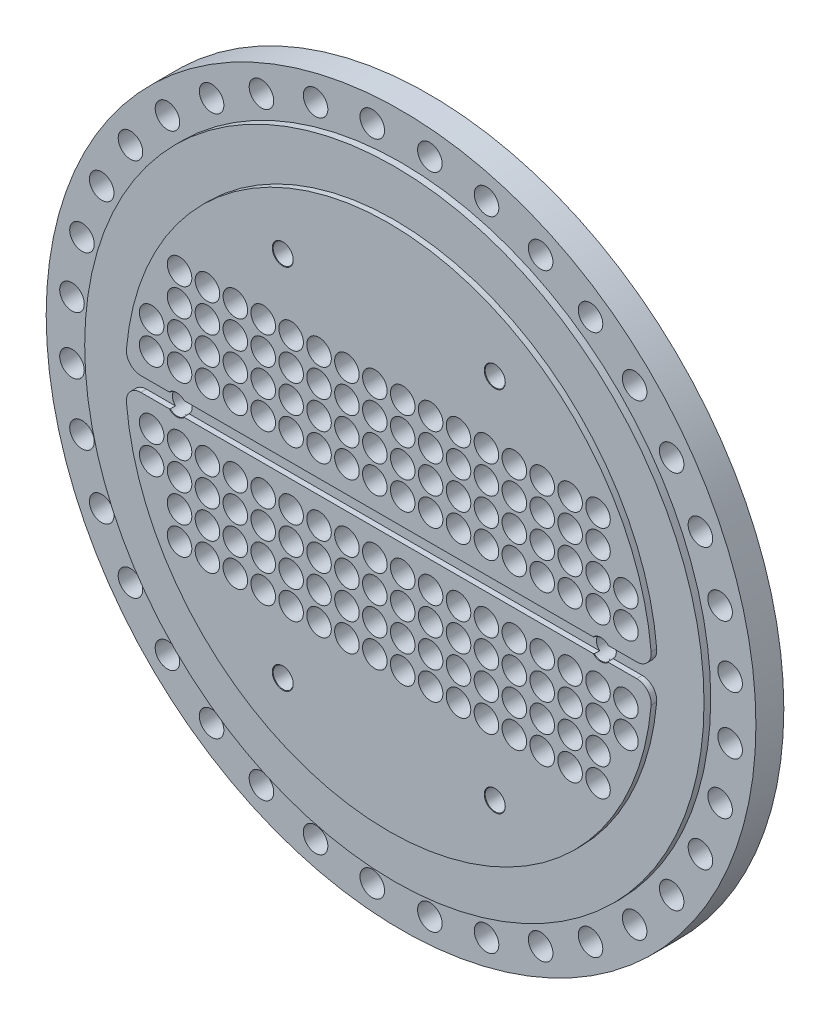
from build123d import *

# Parameters (mm, degrees)
SKETCH1_R                         = 318
BOSS_EXTRUDE1_DEPTH               = 12.5
SKETCH1_3_R                       = 277.5
BOSS_EXTRUDE2_DEPTH               = 18.5
BOSS_EXTRUDE3_DEPTH               = 23.5
SKETCH2_R                         = 11
CUT_EXTRUDE1_DEPTH                = 25
SKETCH3_R                         = 11
CUT_EXTRUDE2_DEPTH                = 47
F_3_8_NPT_TAPPED_HOLE1_AT_2_COUNT = 2
F_3_8_NPT_TAPPED_HOLE1_AT_2_PITCH = 190
F_3_8_NPT_TAPPED_HOLE1_AT_3_COUNT = 2
F_3_8_NPT_TAPPED_HOLE1_AT_3_PITCH = 329.089653438
F_3_8_NPT_TAPPED_HOLE1_AT_4_COUNT = 2
F_3_8_NPT_TAPPED_HOLE1_AT_4_PITCH = 190
F_3_8_NPT_TAPPED_HOLE1_AT_5_COUNT = 2
F_3_8_NPT_TAPPED_HOLE1_AT_5_PITCH = 329.089653438
F_3_8_NPT_TAPPED_HOLE1_AT_6_COUNT = 2
F_3_8_NPT_TAPPED_HOLE1_AT_6_PITCH = 380


with BuildPart() as part:
    # Sketch1 → Boss-Extrude1 (new body, symmetric)
    with BuildSketch(Plane.XY):
        Circle(SKETCH1_R)
    extrude(amount=BOSS_EXTRUDE1_DEPTH, both=True)

    # Sketch1_3 → Boss-Extrude2 (add, symmetric)
    with BuildSketch(Plane.XY):
        Circle(SKETCH1_3_R)
    extrude(amount=BOSS_EXTRUDE2_DEPTH, both=True)

    # Sketch1_4 → Boss-Extrude3 (add, symmetric)
    with BuildSketch(Plane.XY):
        with BuildLine():
            ThreePointArc((-235.095988205, -20.6367713), (-231.731661192, -10.718713844), (-222.145785465, -6.5))
            Line((-222.145785465, -6.5), (222.145785465, -6.5))
            ThreePointArc((222.145785465, -6.5), (231.731661192, -10.718713844), (235.095988205, -20.6367713))
            ThreePointArc((235.095988205, -20.6367713), (0, -236), (-235.095988205, -20.6367713))
        make_face()
        with BuildLine():
            ThreePointArc((235.095988205, 20.6367713), (0, 236), (-235.095988205, 20.6367713))
            ThreePointArc((-235.095988205, 20.6367713), (-231.731661192, 10.718713844), (-222.145785465, 6.5))
            Line((-222.145785465, 6.5), (222.145785465, 6.5))
            ThreePointArc((222.145785465, 6.5), (231.731661192, 10.718713844), (235.095988205, 20.6367713))
        make_face()
    extrude(amount=BOSS_EXTRUDE3_DEPTH, both=True)

    # Sketch2 → Cut-Extrude1 (cut)
    with BuildSketch(Plane.XY.offset(12.5)):
        with Locations((25.798099853, 294.873630635)):
            Circle(SKETCH2_R)
        with Locations((76.61043735, 285.914044582)):
            Circle(SKETCH2_R)
        with Locations((125.095005475, 268.267104963)):
            Circle(SKETCH2_R)
        with Locations((169.77862516, 242.46900511)):
            Circle(SKETCH2_R)
        with Locations((209.303607231, 209.303607231)):
            Circle(SKETCH2_R)
        with Locations((242.46900511, 169.77862516)):
            Circle(SKETCH2_R)
        with Locations((268.267104963, 125.095005475)):
            Circle(SKETCH2_R)
        with Locations((285.914044582, 76.61043735)):
            Circle(SKETCH2_R)
        with Locations((294.873630635, 25.798099853)):
            Circle(SKETCH2_R)
        with Locations((294.873630635, -25.798099853)):
            Circle(SKETCH2_R)
        with Locations((285.914044582, -76.61043735)):
            Circle(SKETCH2_R)
        with Locations((268.267104963, -125.095005475)):
            Circle(SKETCH2_R)
        with Locations((242.46900511, -169.77862516)):
            Circle(SKETCH2_R)
        with Locations((209.303607231, -209.303607231)):
            Circle(SKETCH2_R)
        with Locations((169.77862516, -242.46900511)):
            Circle(SKETCH2_R)
        with Locations((125.095005475, -268.267104963)):
            Circle(SKETCH2_R)
        with Locations((76.61043735, -285.914044582)):
            Circle(SKETCH2_R)
        with Locations((25.798099853, -294.873630635)):
            Circle(SKETCH2_R)
        with Locations((-25.798099853, -294.873630635)):
            Circle(SKETCH2_R)
        with Locations((-76.61043735, -285.914044582)):
            Circle(SKETCH2_R)
        with Locations((-125.095005475, -268.267104963)):
            Circle(SKETCH2_R)
        with Locations((-169.77862516, -242.46900511)):
            Circle(SKETCH2_R)
        with Locations((-209.303607231, -209.303607231)):
            Circle(SKETCH2_R)
        with Locations((-242.46900511, -169.77862516)):
            Circle(SKETCH2_R)
        with Locations((-268.267104963, -125.095005475)):
            Circle(SKETCH2_R)
        with Locations((-285.914044582, -76.61043735)):
            Circle(SKETCH2_R)
        with Locations((-294.873630635, -25.798099853)):
            Circle(SKETCH2_R)
        with Locations((-294.873630635, 25.798099853)):
            Circle(SKETCH2_R)
        with Locations((-285.914044582, 76.61043735)):
            Circle(SKETCH2_R)
        with Locations((-268.267104963, 125.095005475)):
            Circle(SKETCH2_R)
        with Locations((-242.46900511, 169.77862516)):
            Circle(SKETCH2_R)
        with Locations((-209.303607231, 209.303607231)):
            Circle(SKETCH2_R)
        with Locations((-169.77862516, 242.46900511)):
            Circle(SKETCH2_R)
        with Locations((-125.095005475, 268.267104963)):
            Circle(SKETCH2_R)
        with Locations((-76.61043735, 285.914044582)):
            Circle(SKETCH2_R)
        with Locations((-25.798099853, 294.873630635)):
            Circle(SKETCH2_R)
    extrude(amount=-CUT_EXTRUDE1_DEPTH, mode=Mode.SUBTRACT)

    # Sketch3 → Cut-Extrude2 (cut)
    with BuildSketch(Plane.XY.offset(23.5)):
        with Locations((12.5, 30)):
            Circle(SKETCH3_R)
        with Locations((37.5, 30)):
            Circle(SKETCH3_R)
        with Locations((62.5, 30)):
            Circle(SKETCH3_R)
        with Locations((87.5, 30)):
            Circle(SKETCH3_R)
        with Locations((112.5, 30)):
            Circle(SKETCH3_R)
        with Locations((137.5, 30)):
            Circle(SKETCH3_R)
        with Locations((162.5, 30)):
            Circle(SKETCH3_R)
        with Locations((187.5, 30)):
            Circle(SKETCH3_R)
        with Locations((212.5, 30)):
            Circle(SKETCH3_R)
        with Locations((37.5, 55)):
            Circle(SKETCH3_R)
        with Locations((62.5, 55)):
            Circle(SKETCH3_R)
        with Locations((87.5, 55)):
            Circle(SKETCH3_R)
        with Locations((112.5, 55)):
            Circle(SKETCH3_R)
        with Locations((137.5, 55)):
            Circle(SKETCH3_R)
        with Locations((162.5, 55)):
            Circle(SKETCH3_R)
        with Locations((187.5, 55)):
            Circle(SKETCH3_R)
        with Locations((212.5, 55)):
            Circle(SKETCH3_R)
        with Locations((37.5, 80)):
            Circle(SKETCH3_R)
        with Locations((62.5, 80)):
            Circle(SKETCH3_R)
        with Locations((87.5, 80)):
            Circle(SKETCH3_R)
        with Locations((112.5, 80)):
            Circle(SKETCH3_R)
        with Locations((137.5, 80)):
            Circle(SKETCH3_R)
        with Locations((162.5, 80)):
            Circle(SKETCH3_R)
        with Locations((187.5, 80)):
            Circle(SKETCH3_R)
        with Locations((37.5, 105)):
            Circle(SKETCH3_R)
        with Locations((62.5, 105)):
            Circle(SKETCH3_R)
        with Locations((87.5, 105)):
            Circle(SKETCH3_R)
        with Locations((112.5, 105)):
            Circle(SKETCH3_R)
        with Locations((137.5, 105)):
            Circle(SKETCH3_R)
        with Locations((162.5, 105)):
            Circle(SKETCH3_R)
        with Locations((187.5, 105)):
            Circle(SKETCH3_R)
        with Locations((12.5, 55)):
            Circle(SKETCH3_R)
        with Locations((12.5, 80)):
            Circle(SKETCH3_R)
        with Locations((12.5, 105)):
            Circle(SKETCH3_R)
        with Locations((-12.5, 105)):
            Circle(SKETCH3_R)
        with Locations((-12.5, 80)):
            Circle(SKETCH3_R)
        with Locations((-12.5, 55)):
            Circle(SKETCH3_R)
        with Locations((-187.5, 105)):
            Circle(SKETCH3_R)
        with Locations((-162.5, 105)):
            Circle(SKETCH3_R)
        with Locations((-137.5, 105)):
            Circle(SKETCH3_R)
        with Locations((-112.5, 105)):
            Circle(SKETCH3_R)
        with Locations((-87.5, 105)):
            Circle(SKETCH3_R)
        with Locations((-62.5, 105)):
            Circle(SKETCH3_R)
        with Locations((-37.5, 105)):
            Circle(SKETCH3_R)
        with Locations((-187.5, 80)):
            Circle(SKETCH3_R)
        with Locations((-162.5, 80)):
            Circle(SKETCH3_R)
        with Locations((-137.5, 80)):
            Circle(SKETCH3_R)
        with Locations((-112.5, 80)):
            Circle(SKETCH3_R)
        with Locations((-87.5, 80)):
            Circle(SKETCH3_R)
        with Locations((-62.5, 80)):
            Circle(SKETCH3_R)
        with Locations((-37.5, 80)):
            Circle(SKETCH3_R)
        with Locations((-212.5, 55)):
            Circle(SKETCH3_R)
        with Locations((-187.5, 55)):
            Circle(SKETCH3_R)
        with Locations((-162.5, 55)):
            Circle(SKETCH3_R)
        with Locations((-137.5, 55)):
            Circle(SKETCH3_R)
        with Locations((-112.5, 55)):
            Circle(SKETCH3_R)
        with Locations((-87.5, 55)):
            Circle(SKETCH3_R)
        with Locations((-62.5, 55)):
            Circle(SKETCH3_R)
        with Locations((-37.5, 55)):
            Circle(SKETCH3_R)
        with Locations((-212.5, 30)):
            Circle(SKETCH3_R)
        with Locations((-187.5, 30)):
            Circle(SKETCH3_R)
        with Locations((-162.5, 30)):
            Circle(SKETCH3_R)
        with Locations((-137.5, 30)):
            Circle(SKETCH3_R)
        with Locations((-112.5, 30)):
            Circle(SKETCH3_R)
        with Locations((-87.5, 30)):
            Circle(SKETCH3_R)
        with Locations((-62.5, 30)):
            Circle(SKETCH3_R)
        with Locations((-37.5, 30)):
            Circle(SKETCH3_R)
        with Locations((-12.5, 30)):
            Circle(SKETCH3_R)
        with Locations((-212.5, -30)):
            Circle(SKETCH3_R)
        with Locations((-212.5, -55)):
            Circle(SKETCH3_R)
        with Locations((-12.5, -30)):
            Circle(SKETCH3_R)
        with Locations((-37.5, -30)):
            Circle(SKETCH3_R)
        with Locations((-62.5, -30)):
            Circle(SKETCH3_R)
        with Locations((-87.5, -30)):
            Circle(SKETCH3_R)
        with Locations((-112.5, -30)):
            Circle(SKETCH3_R)
        with Locations((-137.5, -30)):
            Circle(SKETCH3_R)
        with Locations((-162.5, -30)):
            Circle(SKETCH3_R)
        with Locations((-187.5, -30)):
            Circle(SKETCH3_R)
        with Locations((-37.5, -55)):
            Circle(SKETCH3_R)
        with Locations((-62.5, -55)):
            Circle(SKETCH3_R)
        with Locations((-87.5, -55)):
            Circle(SKETCH3_R)
        with Locations((-112.5, -55)):
            Circle(SKETCH3_R)
        with Locations((-137.5, -55)):
            Circle(SKETCH3_R)
        with Locations((-162.5, -55)):
            Circle(SKETCH3_R)
        with Locations((-187.5, -55)):
            Circle(SKETCH3_R)
        with Locations((-37.5, -80)):
            Circle(SKETCH3_R)
        with Locations((-62.5, -80)):
            Circle(SKETCH3_R)
        with Locations((-87.5, -80)):
            Circle(SKETCH3_R)
        with Locations((-112.5, -80)):
            Circle(SKETCH3_R)
        with Locations((-137.5, -80)):
            Circle(SKETCH3_R)
        with Locations((-162.5, -80)):
            Circle(SKETCH3_R)
        with Locations((-187.5, -80)):
            Circle(SKETCH3_R)
        with Locations((-37.5, -105)):
            Circle(SKETCH3_R)
        with Locations((-62.5, -105)):
            Circle(SKETCH3_R)
        with Locations((-87.5, -105)):
            Circle(SKETCH3_R)
        with Locations((-112.5, -105)):
            Circle(SKETCH3_R)
        with Locations((-137.5, -105)):
            Circle(SKETCH3_R)
        with Locations((-162.5, -105)):
            Circle(SKETCH3_R)
        with Locations((-187.5, -105)):
            Circle(SKETCH3_R)
        with Locations((-12.5, -55)):
            Circle(SKETCH3_R)
        with Locations((-12.5, -80)):
            Circle(SKETCH3_R)
        with Locations((-12.5, -105)):
            Circle(SKETCH3_R)
        with Locations((12.5, -105)):
            Circle(SKETCH3_R)
        with Locations((12.5, -80)):
            Circle(SKETCH3_R)
        with Locations((12.5, -55)):
            Circle(SKETCH3_R)
        with Locations((187.5, -105)):
            Circle(SKETCH3_R)
        with Locations((162.5, -105)):
            Circle(SKETCH3_R)
        with Locations((137.5, -105)):
            Circle(SKETCH3_R)
        with Locations((112.5, -105)):
            Circle(SKETCH3_R)
        with Locations((87.5, -105)):
            Circle(SKETCH3_R)
        with Locations((62.5, -105)):
            Circle(SKETCH3_R)
        with Locations((37.5, -105)):
            Circle(SKETCH3_R)
        with Locations((187.5, -80)):
            Circle(SKETCH3_R)
        with Locations((162.5, -80)):
            Circle(SKETCH3_R)
        with Locations((137.5, -80)):
            Circle(SKETCH3_R)
        with Locations((112.5, -80)):
            Circle(SKETCH3_R)
        with Locations((87.5, -80)):
            Circle(SKETCH3_R)
        with Locations((62.5, -80)):
            Circle(SKETCH3_R)
        with Locations((37.5, -80)):
            Circle(SKETCH3_R)
        with Locations((212.5, -55)):
            Circle(SKETCH3_R)
        with Locations((187.5, -55)):
            Circle(SKETCH3_R)
        with Locations((162.5, -55)):
            Circle(SKETCH3_R)
        with Locations((137.5, -55)):
            Circle(SKETCH3_R)
        with Locations((112.5, -55)):
            Circle(SKETCH3_R)
        with Locations((87.5, -55)):
            Circle(SKETCH3_R)
        with Locations((62.5, -55)):
            Circle(SKETCH3_R)
        with Locations((37.5, -55)):
            Circle(SKETCH3_R)
        with Locations((212.5, -30)):
            Circle(SKETCH3_R)
        with Locations((187.5, -30)):
            Circle(SKETCH3_R)
        with Locations((162.5, -30)):
            Circle(SKETCH3_R)
        with Locations((137.5, -30)):
            Circle(SKETCH3_R)
        with Locations((112.5, -30)):
            Circle(SKETCH3_R)
        with Locations((87.5, -30)):
            Circle(SKETCH3_R)
        with Locations((62.5, -30)):
            Circle(SKETCH3_R)
        with Locations((37.5, -30)):
            Circle(SKETCH3_R)
        with Locations((12.5, -30)):
            Circle(SKETCH3_R)
    extrude(amount=-CUT_EXTRUDE2_DEPTH, mode=Mode.SUBTRACT)

    # Sketch6 → 3_8 NPT Tapped Hole1 (revolve, cut)
    with BuildSketch(Plane(origin=(-95, -164.544826719, 23.5), x_dir=(0, -1, 0), z_dir=(1, 0, 0))):
        Polygon((0, 0), (0, 36.288582582), (7.1374, 32), (7.1374, 25), (8.274761477, 25), (9.0117295, 0.3862705), (9.398, 0), align=None)
    f_3_8_npt_tapped_hole1 = revolve(axis=Axis((-95, -164.544826719, 29.85), (0, 0, -1)), mode=Mode.SUBTRACT)

    # 3_8 NPT Tapped Hole1 at 2: 3_8 NPT Tapped Hole1 ×2
    with Locations(*[(i * F_3_8_NPT_TAPPED_HOLE1_AT_2_PITCH, 0, 0) for i in range(1, F_3_8_NPT_TAPPED_HOLE1_AT_2_COUNT)]):
        add(f_3_8_npt_tapped_hole1, mode=Mode.SUBTRACT)

    # 3_8 NPT Tapped Hole1 at 3: 3_8 NPT Tapped Hole1 ×2
    with Locations(*[Vector(0.866025404, 0.5, 0) * (i * F_3_8_NPT_TAPPED_HOLE1_AT_3_PITCH) for i in range(1, F_3_8_NPT_TAPPED_HOLE1_AT_3_COUNT)]):
        add(f_3_8_npt_tapped_hole1, mode=Mode.SUBTRACT)

    # 3_8 NPT Tapped Hole1 at 4: 3_8 NPT Tapped Hole1 ×2
    with Locations(*[Vector(-0.5, 0.866025404, 0) * (i * F_3_8_NPT_TAPPED_HOLE1_AT_4_PITCH) for i in range(1, F_3_8_NPT_TAPPED_HOLE1_AT_4_COUNT)]):
        add(f_3_8_npt_tapped_hole1, mode=Mode.SUBTRACT)

    # 3_8 NPT Tapped Hole1 at 5: 3_8 NPT Tapped Hole1 ×2
    with Locations(*[(0, i * F_3_8_NPT_TAPPED_HOLE1_AT_5_PITCH, 0) for i in range(1, F_3_8_NPT_TAPPED_HOLE1_AT_5_COUNT)]):
        add(f_3_8_npt_tapped_hole1, mode=Mode.SUBTRACT)

    # 3_8 NPT Tapped Hole1 at 6: 3_8 NPT Tapped Hole1 ×2
    with Locations(*[Vector(0.5, 0.866025404, 0) * (i * F_3_8_NPT_TAPPED_HOLE1_AT_6_PITCH) for i in range(1, F_3_8_NPT_TAPPED_HOLE1_AT_6_COUNT)]):
        add(f_3_8_npt_tapped_hole1, mode=Mode.SUBTRACT)


solid = part.part
